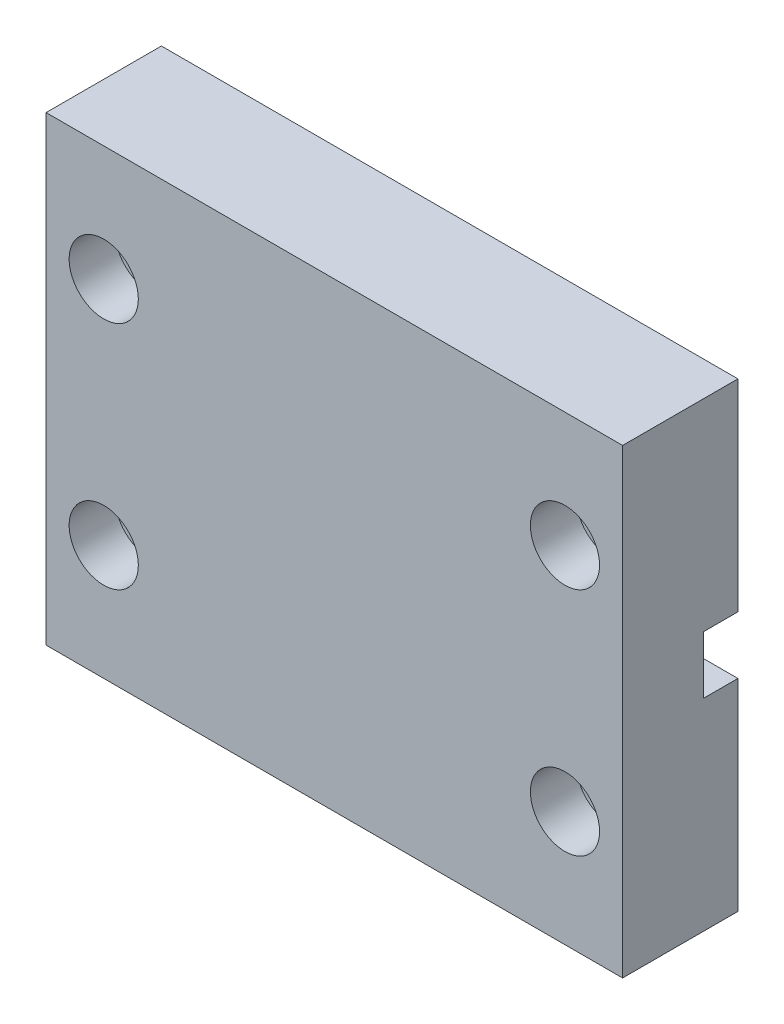
from build123d import *

# Parameters (mm, degrees)
SKETCH1_W           = 50
SKETCH1_H           = 10
BOSS_EXTRUDE1_DEPTH = 40
CUT_EXTRUDE1_REACH  = 12
SKETCH2_R           = 1.75
SKETCH3_R           = 3
CUT_EXTRUDE2_DEPTH  = 4
SKETCH5_R           = 2.5
CUT_EXTRUDE3_DEPTH  = 8
SKETCH6_W           = 20
SKETCH6_H           = 5
CUT_EXTRUDE4_DEPTH  = 3


with BuildPart() as part:
    # Sketch1 → Boss-Extrude1 (new body)
    with BuildSketch(Plane(origin=(0, 0.83575208, 0), x_dir=(-1, 0, 0), z_dir=(0, 1, 0))):
        with Locations((0.444640388, 23.28984466)):
            Rectangle(SKETCH1_W, SKETCH1_H)
    extrude(amount=BOSS_EXTRUDE1_DEPTH)

    # Sketch2 → Cut-Extrude1 (cut, up to next)
    with BuildSketch(Plane.XY.offset(28.28984466), mode=Mode.PRIVATE) as cut_extrude1_sk1:
        with Locations((-20.444640388, 30.83575208)):
            Circle(SKETCH2_R)
    cut_extrude1_tool1 = extrude(cut_extrude1_sk1.sketch, amount=-CUT_EXTRUDE1_REACH, mode=Mode.PRIVATE) & part.part
    add(cut_extrude1_tool1.solids().sort_by_distance((-20.44464, 30.835752, 28.289845))[0], mode=Mode.SUBTRACT)
    # Sketch2 → Cut-Extrude1 (cut, up to next)
    with BuildSketch(Plane.XY.offset(28.28984466), mode=Mode.PRIVATE) as cut_extrude1_sk2:
        with Locations((-20.444640388, 10.83575208)):
            Circle(SKETCH2_R)
    cut_extrude1_tool2 = extrude(cut_extrude1_sk2.sketch, amount=-CUT_EXTRUDE1_REACH, mode=Mode.PRIVATE) & part.part
    add(cut_extrude1_tool2.solids().sort_by_distance((-20.44464, 10.835752, 28.289845))[0], mode=Mode.SUBTRACT)
    # Sketch2 → Cut-Extrude1 (cut, up to next)
    with BuildSketch(Plane.XY.offset(28.28984466), mode=Mode.PRIVATE) as cut_extrude1_sk3:
        with Locations((19.555359612, 10.83575208)):
            Circle(SKETCH2_R)
    cut_extrude1_tool3 = extrude(cut_extrude1_sk3.sketch, amount=-CUT_EXTRUDE1_REACH, mode=Mode.PRIVATE) & part.part
    add(cut_extrude1_tool3.solids().sort_by_distance((19.55536, 10.835752, 28.289845))[0], mode=Mode.SUBTRACT)
    # Sketch2 → Cut-Extrude1 (cut, up to next)
    with BuildSketch(Plane.XY.offset(28.28984466), mode=Mode.PRIVATE) as cut_extrude1_sk4:
        with Locations((19.555359612, 30.83575208)):
            Circle(SKETCH2_R)
    cut_extrude1_tool4 = extrude(cut_extrude1_sk4.sketch, amount=-CUT_EXTRUDE1_REACH, mode=Mode.PRIVATE) & part.part
    add(cut_extrude1_tool4.solids().sort_by_distance((19.55536, 30.835752, 28.289845))[0], mode=Mode.SUBTRACT)

    # Sketch3 → Cut-Extrude2 (cut)
    with BuildSketch(Plane.XY.offset(28.28984466)):
        with Locations((-20.444640388, 30.83575208)):
            Circle(SKETCH3_R)
        with Locations((-20.444640388, 10.83575208)):
            Circle(SKETCH3_R)
        with Locations((19.555359612, 10.83575208)):
            Circle(SKETCH3_R)
        with Locations((19.555359612, 30.83575208)):
            Circle(SKETCH3_R)
    extrude(amount=-CUT_EXTRUDE2_DEPTH, mode=Mode.SUBTRACT)

    # Sketch5 → Cut-Extrude3 (cut)
    with BuildSketch(Plane(origin=(0, 0, 18.28984466), x_dir=(-1, 0, 0), z_dir=(0, 0, -1))):
        with Locations((5.444640388, 20.83575208)):
            Circle(SKETCH5_R)
        with Locations((-4.555359612, 20.83575208)):
            Circle(SKETCH5_R)
    extrude(amount=-CUT_EXTRUDE3_DEPTH, mode=Mode.SUBTRACT)

    # Sketch6 → Cut-Extrude4 (cut)
    with BuildSketch(Plane(origin=(0, 0, 18.28984466), x_dir=(-1, 0, 0), z_dir=(0, 0, -1))):
        with Locations((15.444640388, 20.83575208)):
            Rectangle(SKETCH6_W, SKETCH6_H)
        with Locations((-14.555359612, 20.83575208)):
            Rectangle(SKETCH6_W, SKETCH6_H)
    extrude(amount=-CUT_EXTRUDE4_DEPTH, mode=Mode.SUBTRACT)


solid = part.part
